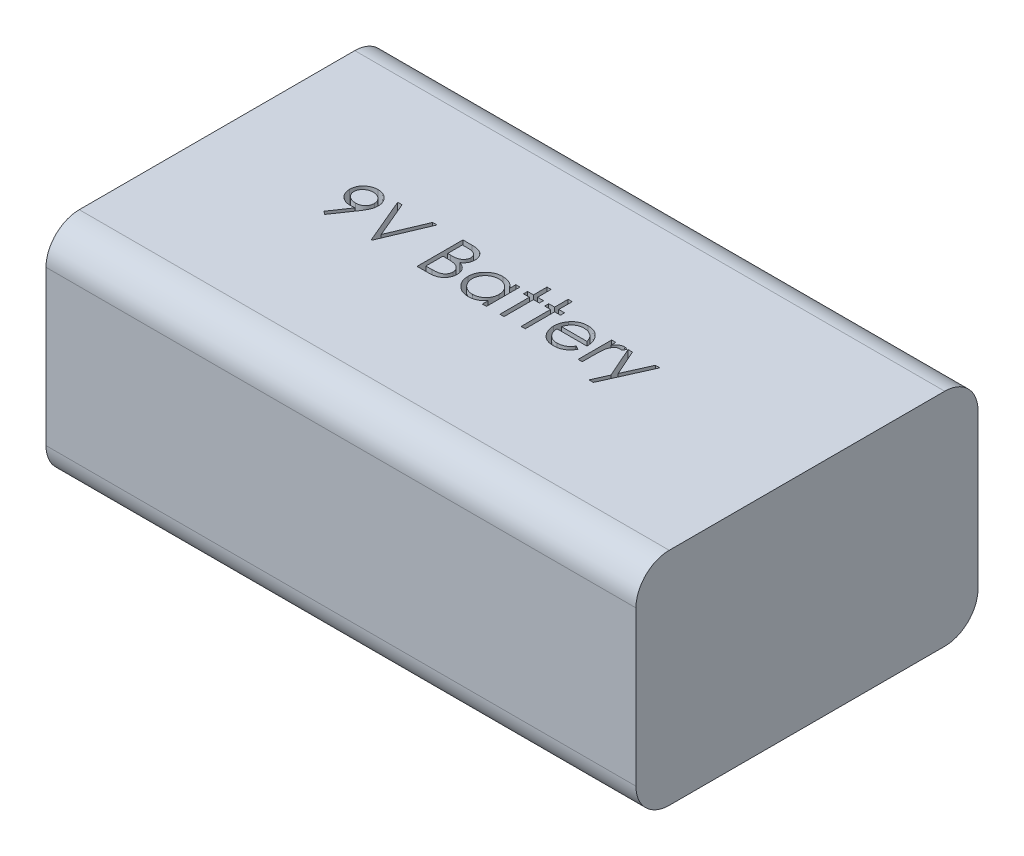
from build123d import *

# Parameters (mm, degrees)
SKETCH1_W           = 47.5742
SKETCH1_H           = 26.1112
BOSS_EXTRUDE1_DEPTH = 16.8656
CUT_EXTRUDE1_DEPTH  = 1.778
SKETCH3_W           = 26.1112
SKETCH3_H           = 16.8656
SKETCH3_R           = 3.81
CUT_EXTRUDE2_DEPTH  = 2.54
FILLET2_R           = 2.54


with BuildPart() as part:
    # Sketch1 → Boss-Extrude1 (new body)
    with BuildSketch(Plane(origin=(0, 0, 0), x_dir=(1, 0, 0), z_dir=(0, 1, 0))):
        with Locations((23.7871, 13.0556)):
            Rectangle(SKETCH1_W, SKETCH1_H)
    extrude(amount=BOSS_EXTRUDE1_DEPTH)

    # Sketch2 → Cut-Extrude1 (cut)
    with BuildSketch(Plane(origin=(0, 16.8656, 0), x_dir=(1, 0, 0), z_dir=(0, 1, 0))):
        with BuildLine():
            Line((12.226093924, 11.595445946), (11.975092322, 11.770025272))
            Line((11.975092322, 11.770025272), (12.948249373, 13.192601394))
            add(Edge.make_bspline(
                [(12.948249373, 13.192601394), (12.886158637, 13.185008331), (12.763898517, 13.170057166), (12.640761415, 13.167310511), (12.58016043, 13.165958766)],
                knots=[0, 0, 0, 0, 0.000187529, 0.000369255, 0.000369255, 0.000369255, 0.000369255], degree=3))
            add(Edge.make_bspline(
                [(12.58016043, 13.165958766), (12.543418383, 13.166899843), (12.471296956, 13.168747093), (12.365265303, 13.183388902), (12.263379743, 13.205939029), (12.165910387, 13.239587784), (12.072490882, 13.281405993), (11.983325169, 13.333263007), (11.898533278, 13.394269299), (11.819025868, 13.46410229), (11.746714129, 13.540780343), (11.682290831, 13.621935986), (11.6287497, 13.708511956), (11.584273114, 13.798742176), (11.550542661, 13.893923527), (11.525980123, 13.992972927), (11.510857769, 14.096584569), (11.509058673, 14.1671097), (11.508145206, 14.202917901)],
                knots=[0, 0, 0, 0, 0.000110185, 0.000216284, 0.000320547, 0.000422759, 0.000525058, 0.000627155, 0.000731643, 0.000837964, 0.0009441, 0.00104747, 0.001148247, 0.001248901, 0.001348697, 0.001450555, 0.001554666, 0.00166205, 0.00166205, 0.00166205, 0.00166205], degree=3))
            add(Edge.make_bspline(
                [(11.508145206, 14.202917901), (11.509879641, 14.251886553), (11.513283985, 14.348002085), (11.540682502, 14.488435854), (11.585742841, 14.621222398), (11.648571218, 14.746012591), (11.727705939, 14.861011331), (11.822814529, 14.96461994), (11.933318494, 15.055364794), (12.056700513, 15.133368871), (12.190053534, 15.196103868), (12.329722192, 15.242343169), (12.474636312, 15.269541917), (12.572803982, 15.273127778), (12.622227738, 15.274933125)],
                knots=[0, 0, 0, 0, 0.000146818, 0.000288173, 0.000427413, 0.000566316, 0.000705952, 0.000844895, 0.000986821, 0.001133677, 0.001281714, 0.001427825, 0.001574003, 0.00172222, 0.00172222, 0.00172222, 0.00172222], degree=3))
            add(Edge.make_bspline(
                [(12.622227738, 15.274933125), (12.670716158, 15.273102962), (12.766524705, 15.269486732), (12.907413711, 15.243002763), (13.042354728, 15.19836609), (13.170599715, 15.136681527), (13.289339127, 15.059360619), (13.396114938, 14.967226095), (13.488490477, 14.860220568), (13.566314358, 14.740932078), (13.628784398, 14.612765097), (13.673856681, 14.478981174), (13.70160232, 14.340542453), (13.705098647, 14.246747979), (13.706863155, 14.199412292)],
                knots=[0, 0, 0, 0, 0.000145418, 0.000287333, 0.000428343, 0.000570713, 0.000713061, 0.00085223, 0.000992387, 0.001135706, 0.001278381, 0.001418948, 0.001558239, 0.001700158, 0.001700158, 0.001700158, 0.001700158], degree=3))
            add(Edge.make_bspline(
                [(13.706863155, 14.199412292), (13.705684746, 14.162668525), (13.703294638, 14.088142984), (13.686558331, 13.974912641), (13.658138146, 13.859461412), (13.625886447, 13.761739816), (13.594754279, 13.681031366), (13.565453148, 13.617279786), (13.532940994, 13.550178523), (13.495022229, 13.480431185), (13.454259932, 13.40714865), (13.408200656, 13.331065934), (13.357895084, 13.252080941), (13.322065364, 13.198833853), (13.303718123, 13.17156774)],
                knots=[0, 0, 0, 0, 0.000110219, 0.000223552, 0.000342587, 0.000466527, 0.000532018, 0.000601997, 0.000676938, 0.00075567, 0.000840114, 0.000928491, 0.001022434, 0.001121023, 0.001121023, 0.001121023, 0.001121023], degree=3))
            Line((13.303718123, 13.17156774), (12.226093924, 11.595445946))
        make_face()
        with BuildLine():
            add(Edge.make_bspline(
                [(12.638353539, 13.524933125), (12.666187554, 13.525693509), (12.720370917, 13.527173717), (12.799748216, 13.536182959), (12.874672419, 13.552156945), (12.945343668, 13.575076658), (13.01247057, 13.602733326), (13.074986899, 13.637945313), (13.132944974, 13.679961947), (13.186732901, 13.727171963), (13.234496901, 13.779622547), (13.277039931, 13.834519653), (13.313200499, 13.892104263), (13.341763776, 13.953097526), (13.365248351, 14.016014734), (13.381466363, 14.081869089), (13.390450697, 14.15031749), (13.391982271, 14.196816148), (13.392760591, 14.220445946)],
                knots=[0, 0, 0, 0, 8.3507e-05, 0.00016256, 0.000239294, 0.000312908, 0.000385178, 0.000456751, 0.000527578, 0.000599603, 0.000671055, 0.000740051, 0.000807755, 0.000874553, 0.000941763, 0.001008931, 0.001077548, 0.001148448, 0.001148448, 0.001148448, 0.001148448], degree=3))
            add(Edge.make_bspline(
                [(13.392760591, 14.220445946), (13.392090922, 14.244085611), (13.390771256, 14.290670471), (13.380183957, 14.359220211), (13.361558733, 14.424913471), (13.336568249, 14.488109901), (13.303648011, 14.548290273), (13.264144525, 14.606210145), (13.217212075, 14.661502273), (13.163209509, 14.712866256), (13.104974956, 14.760214156), (13.042914456, 14.802000232), (12.97753954, 14.837021428), (12.90924905, 14.865920398), (12.837900701, 14.888472174), (12.763536713, 14.904689538), (12.685781308, 14.913661293), (12.633000021, 14.915183187), (12.606101937, 14.915958766)],
                knots=[0, 0, 0, 0, 7.09e-05, 0.000139717, 0.000207422, 0.000275384, 0.000343146, 0.000412766, 0.000485392, 0.000560268, 0.000636041, 0.000710323, 0.000784354, 0.000858188, 0.000932471, 0.001008519, 0.001086179, 0.001166885, 0.001166885, 0.001166885, 0.001166885], degree=3))
            add(Edge.make_bspline(
                [(12.606101937, 14.915958766), (12.579437784, 14.915181934), (12.527122934, 14.913657797), (12.450058775, 14.904706592), (12.376197607, 14.888363108), (12.305055987, 14.865930844), (12.236767526, 14.837019272), (12.171395693, 14.801998397), (12.109320677, 14.760223774), (12.051141956, 14.712829002), (11.997044034, 14.661741356), (11.950918505, 14.605967927), (11.911324613, 14.548320402), (11.87844961, 14.488101894), (11.853447093, 14.424915609), (11.834825091, 14.359219632), (11.824236926, 14.290670622), (11.822917379, 14.244085662), (11.82224777, 14.220445946)],
                knots=[0, 0, 0, 0, 8.0005e-05, 0.000156969, 0.000232332, 0.000306614, 0.000380449, 0.000454479, 0.000528762, 0.000604535, 0.000679411, 0.000751586, 0.000821205, 0.000888968, 0.00095693, 0.001024634, 0.001093451, 0.001164351, 0.001164351, 0.001164351, 0.001164351], degree=3))
            add(Edge.make_bspline(
                [(11.82224777, 14.220445946), (11.822853696, 14.196797747), (11.824048694, 14.150159171), (11.835576483, 14.081632778), (11.854854763, 14.015944584), (11.880674154, 13.952455877), (11.914675744, 13.891784019), (11.956399592, 13.834216657), (12.005305138, 13.779101207), (12.060738626, 13.727293995), (12.121406786, 13.679741819), (12.186203533, 13.638211437), (12.254013369, 13.603138993), (12.325075, 13.574997609), (12.3988618, 13.552385945), (12.476036932, 13.5362124), (12.556345169, 13.527260133), (12.610755151, 13.525716236), (12.638353539, 13.524933125)],
                knots=[0, 0, 0, 0, 7.09e-05, 0.000139828, 0.000207725, 0.00027595, 0.000345002, 0.000415829, 0.000488844, 0.000565728, 0.000643147, 0.000719775, 0.000796287, 0.0008718, 0.000948761, 0.001027552, 0.001107998, 0.001190805, 0.001190805, 0.001190805, 0.001190805], degree=3))
        make_face(mode=Mode.SUBTRACT)
        Polygon((14.200452898, 15.185189535), (14.53699136, 15.185189535), (15.703658027, 12.426976394), (16.870324693, 15.185189535), (17.206863155, 15.185189535), (15.726093924, 11.685189535), (15.681222129, 11.685189535), align=None)
        with BuildLine():
            Line((19.181222129, 15.185189535), (19.864114757, 15.185189535))
            add(Edge.make_bspline(
                [(19.864114757, 15.185189535), (19.897543236, 15.185013785), (19.962335946, 15.184673137), (20.056555388, 15.179390006), (20.144804198, 15.172186336), (20.227107971, 15.160756243), (20.303428673, 15.146964466), (20.37399631, 15.13026265), (20.438586483, 15.110236036), (20.515699219, 15.078389755), (20.60361988, 15.031066587), (20.698818273, 14.961138022), (20.780222512, 14.875605558), (20.850408829, 14.779122903), (20.906209949, 14.672987131), (20.946579246, 14.559727942), (20.972137122, 14.440806201), (20.974765556, 14.359163023), (20.976093924, 14.317901875)],
                knots=[0, 0, 0, 0, 0.00010027, 0.000194349, 0.000283026, 0.000365821, 0.000443519, 0.000515622, 0.000583254, 0.00064614, 0.000765662, 0.000881909, 0.000998927, 0.001118415, 0.001238844, 0.00135727, 0.001478274, 0.001601912, 0.001601912, 0.001601912, 0.001601912], degree=3))
            add(Edge.make_bspline(
                [(20.976093924, 14.317901875), (20.975000706, 14.279249319), (20.972852428, 14.203293402), (20.952309669, 14.092199293), (20.920149001, 13.986448074), (20.875443751, 13.886425689), (20.817341755, 13.794392076), (20.748483437, 13.70960481), (20.665406634, 13.635653753), (20.603163394, 13.59431085), (20.571546648, 13.573310529)],
                knots=[0, 0, 0, 0, 0.000115857, 0.00022767, 0.000337672, 0.000446877, 0.000555233, 0.000663318, 0.000773539, 0.000887324, 0.000887324, 0.000887324, 0.000887324], degree=3))
            add(Edge.make_bspline(
                [(20.571546648, 13.573310529), (20.611307076, 13.55804553), (20.687378623, 13.528839806), (20.792064636, 13.477204342), (20.882259481, 13.421042231), (20.958656627, 13.359710381), (21.023994282, 13.29360157), (21.081047223, 13.221746456), (21.129728597, 13.143207698), (21.171441521, 13.058804163), (21.203990277, 12.969397694), (21.228366181, 12.875826918), (21.242333631, 12.778427363), (21.244321272, 12.712141984), (21.245324693, 12.678679119)],
                knots=[0, 0, 0, 0, 0.000127722, 0.000244363, 0.000349599, 0.000445847, 0.000537565, 0.000627901, 0.000720503, 0.000814257, 0.000909859, 0.001005428, 0.001103887, 0.001204268, 0.001204268, 0.001204268, 0.001204268], degree=3))
            add(Edge.make_bspline(
                [(21.245324693, 12.678679119), (21.244347847, 12.644512246), (21.242425875, 12.577287968), (21.228245904, 12.478532834), (21.204236797, 12.384157887), (21.17116565, 12.293552705), (21.128003336, 12.20689257), (21.075475371, 12.124079306), (21.012843808, 12.045944975), (20.942780939, 11.971621352), (20.863518793, 11.904793565), (20.778003038, 11.845277858), (20.685156718, 11.796331796), (20.586504724, 11.755215775), (20.480940408, 11.723808576), (20.368937801, 11.701836002), (20.250593499, 11.687030965), (20.169383748, 11.68581376), (20.127736552, 11.685189535)],
                knots=[0, 0, 0, 0, 0.000102481, 0.000201635, 0.000298562, 0.000394165, 0.000490425, 0.000588455, 0.000687769, 0.000790423, 0.000894381, 0.000998232, 0.001102369, 0.001208616, 0.001318415, 0.001432129, 0.001550749, 0.00167562, 0.00167562, 0.00167562, 0.00167562], degree=3))
            Line((20.127736552, 11.685189535), (19.181222129, 11.685189535))
            Line((19.181222129, 11.685189535), (19.181222129, 15.185189535))
        make_face()
        with BuildLine():
            Line((19.495324693, 14.826215176), (19.495324693, 13.704420305))
            Line((19.495324693, 13.704420305), (19.706362354, 13.704420305))
            add(Edge.make_bspline(
                [(19.706362354, 13.704420305), (19.737211149, 13.704820228), (19.796817308, 13.70559296), (19.883137205, 13.707806477), (19.963262223, 13.714004521), (20.037054056, 13.720200783), (20.1043965, 13.73027537), (20.165140361, 13.742267493), (20.220238958, 13.754950398), (20.283778504, 13.776519885), (20.355851452, 13.808397561), (20.432684557, 13.857869397), (20.500419026, 13.91679375), (20.557616214, 13.984784712), (20.604427684, 14.059650897), (20.6369414, 14.140197778), (20.658988684, 14.22441791), (20.660980215, 14.282236163), (20.66199136, 14.311591779)],
                knots=[0, 0, 0, 0, 9.2559e-05, 0.000178842, 0.000258967, 0.000333616, 0.000400942, 0.000463093, 0.000519379, 0.000570374, 0.000664201, 0.000755025, 0.000843472, 0.000932526, 0.001020669, 0.001107124, 0.001192318, 0.001280185, 0.001280185, 0.001280185, 0.001280185], degree=3))
            add(Edge.make_bspline(
                [(20.66199136, 14.311591779), (20.66146518, 14.33101755), (20.66043302, 14.369123322), (20.651979717, 14.424672677), (20.637612143, 14.476916429), (20.61915785, 14.526570539), (20.593369161, 14.57208239), (20.563005698, 14.615025585), (20.526320007, 14.653937704), (20.484562695, 14.690307202), (20.436554072, 14.72255173), (20.38232278, 14.750792493), (20.321135103, 14.77353327), (20.254022248, 14.793449422), (20.17995116, 14.807437716), (20.099776607, 14.819091104), (20.012841888, 14.825023846), (19.952696785, 14.825809209), (19.921606745, 14.826215176)],
                knots=[0, 0, 0, 0, 5.8261e-05, 0.000114285, 0.000168029, 0.000220632, 0.000272728, 0.000324483, 0.000378062, 0.000432741, 0.000490301, 0.000551137, 0.000615721, 0.000685833, 0.000760908, 0.00084162, 0.000928788, 0.00102206, 0.00102206, 0.00102206, 0.00102206], degree=3))
            Line((19.921606745, 14.826215176), (19.495324693, 14.826215176))
        make_face(mode=Mode.SUBTRACT)
        with BuildLine():
            Line((19.495324693, 13.345445946), (19.495324693, 12.044163894))
            Line((19.495324693, 12.044163894), (19.942640398, 12.044163894))
            add(Edge.make_bspline(
                [(19.942640398, 12.044163894), (19.974659324, 12.044547642), (20.036371583, 12.045287264), (20.125472813, 12.047701819), (20.208055917, 12.053194094), (20.283744053, 12.061839944), (20.353354505, 12.071218393), (20.416052208, 12.083829674), (20.472345402, 12.098278635), (20.537619709, 12.120612807), (20.611123218, 12.155309278), (20.690334074, 12.207623504), (20.760760292, 12.269946812), (20.820565551, 12.342077726), (20.86957854, 12.420509053), (20.905233995, 12.503654403), (20.927224852, 12.590139931), (20.929887021, 12.649106643), (20.931222129, 12.678679119)],
                knots=[0, 0, 0, 0, 9.6064e-05, 0.000185151, 0.000267373, 0.000344257, 0.000413665, 0.000478015, 0.000536005, 0.000587888, 0.000684801, 0.000778918, 0.000871787, 0.000965866, 0.001059062, 0.00114827, 0.001236355, 0.001324974, 0.001324974, 0.001324974, 0.001324974], degree=3))
            add(Edge.make_bspline(
                [(20.931222129, 12.678679119), (20.930946025, 12.697172459), (20.93039827, 12.733860841), (20.922137655, 12.78777666), (20.910123785, 12.840002533), (20.894592351, 12.890680274), (20.871972884, 12.93889365), (20.845566339, 12.98559621), (20.814604937, 13.030849689), (20.766360772, 13.088061943), (20.696188787, 13.153978956), (20.596482012, 13.218516458), (20.483109714, 13.270564265), (20.400882221, 13.292663741), (20.358405623, 13.30407976)],
                knots=[0, 0, 0, 0, 5.5429e-05, 0.000109963, 0.000163198, 0.000216191, 0.000268588, 0.000322593, 0.000377046, 0.000432793, 0.000546889, 0.000664343, 0.000787646, 0.000919405, 0.000919405, 0.000919405, 0.000919405], degree=3))
            add(Edge.make_bspline(
                [(20.358405623, 13.30407976), (20.341376527, 13.307534844), (20.304453935, 13.315026178), (20.244246354, 13.322933882), (20.175510485, 13.329978942), (20.098087608, 13.335190099), (20.011879767, 13.340576643), (19.916702848, 13.342671464), (19.812945534, 13.345170724), (19.740953161, 13.345351858), (19.703557866, 13.345445946)],
                knots=[0, 0, 0, 0, 5.2115e-05, 0.000112995, 0.000182062, 0.000259389, 0.000345767, 0.00044116, 0.000544948, 0.000657129, 0.000657129, 0.000657129, 0.000657129], degree=3))
            Line((19.703557866, 13.345445946), (19.495324693, 13.345445946))
        make_face(mode=Mode.SUBTRACT)
        with BuildLine():
            Line((24.476093924, 14.242881843), (24.476093924, 11.685189535))
            Line((24.476093924, 11.685189535), (24.16199136, 11.685189535))
            Line((24.16199136, 11.685189535), (24.16199136, 12.127597388))
            add(Edge.make_bspline(
                [(24.16199136, 12.127597388), (24.126572569, 12.087557794), (24.057452354, 12.009420023), (23.942011236, 11.90733785), (23.819643058, 11.822959529), (23.690941737, 11.754809613), (23.556023494, 11.703617557), (23.415187406, 11.667231398), (23.268376026, 11.643837562), (23.168123671, 11.641501541), (23.117319886, 11.64031774)],
                knots=[0, 0, 0, 0, 0.000160263, 0.000312755, 0.000460949, 0.000605216, 0.000748578, 0.000892786, 0.001041028, 0.001193333, 0.001193333, 0.001193333, 0.001193333], degree=3))
            add(Edge.make_bspline(
                [(23.117319886, 11.64031774), (23.072151932, 11.641544113), (22.983078727, 11.643962573), (22.85204965, 11.662724877), (22.7259574, 11.692855498), (22.604682828, 11.734756388), (22.489010682, 11.790337209), (22.377950586, 11.856878458), (22.272077894, 11.936119288), (22.173006355, 12.026707316), (22.081774354, 12.125102303), (22.001713082, 12.23004785), (21.934960002, 12.341090154), (21.879139921, 12.456823308), (21.836143577, 12.578138227), (21.806169942, 12.704615395), (21.787429496, 12.836105269), (21.785012035, 12.925644792), (21.783786232, 12.971046907)],
                knots=[0, 0, 0, 0, 0.000135464, 0.00026714, 0.000396211, 0.000523931, 0.000651257, 0.000780517, 0.000911767, 0.001047265, 0.00118272, 0.001313831, 0.001442491, 0.001570752, 0.001698704, 0.001827775, 0.001960146, 0.00209631, 0.00209631, 0.00209631, 0.00209631], degree=3))
            add(Edge.make_bspline(
                [(21.783786232, 12.971046907), (21.785039203, 13.015510611), (21.78751626, 13.103412954), (21.80596948, 13.232691652), (21.837000488, 13.357209913), (21.880548336, 13.476566856), (21.936390291, 13.590906906), (22.004318378, 13.700310931), (22.084337503, 13.805080329), (22.17658991, 13.902751555), (22.27652468, 13.99297217), (22.383433411, 14.071381215), (22.494656692, 14.139098064), (22.611919703, 14.19275154), (22.733486808, 14.236160645), (22.860440253, 14.266193613), (22.992251832, 14.283890934), (23.081742324, 14.286453698), (23.127135591, 14.287753638)],
                knots=[0, 0, 0, 0, 0.000133363, 0.00026365, 0.000390846, 0.000517716, 0.000644083, 0.000771912, 0.000903449, 0.001038867, 0.001174416, 0.001306792, 0.001436052, 0.00156435, 0.001692963, 0.001822716, 0.001954992, 0.002091156, 0.002091156, 0.002091156, 0.002091156], degree=3))
            add(Edge.make_bspline(
                [(23.127135591, 14.287753638), (23.17933545, 14.286315886), (23.28169691, 14.283496523), (23.431424919, 14.260033796), (23.573069397, 14.220395329), (23.707723749, 14.166477831), (23.834904435, 14.094829102), (23.953407419, 14.004449141), (24.064472903, 13.895907954), (24.128853194, 13.812537509), (24.16199136, 13.769624631)],
                knots=[0, 0, 0, 0, 0.00015654, 0.000306968, 0.000453261, 0.000596998, 0.000741098, 0.000889738, 0.001042937, 0.001205434, 0.001205434, 0.001205434, 0.001205434], degree=3))
            Line((24.16199136, 13.769624631), (24.16199136, 14.242881843))
            Line((24.16199136, 14.242881843), (24.476093924, 14.242881843))
        make_face()
        with BuildLine():
            add(Edge.make_bspline(
                [(23.131342322, 13.973651074), (23.085427984, 13.972017436), (22.994800384, 13.968792895), (22.861756382, 13.9436194), (22.734442968, 13.901734805), (22.613496893, 13.844452904), (22.500828677, 13.772424168), (22.400135006, 13.685302784), (22.310592304, 13.58546577), (22.23528404, 13.47336366), (22.173893543, 13.353185569), (22.130726511, 13.227561131), (22.102257264, 13.098756153), (22.099348743, 13.011393467), (22.097888796, 12.967541298)],
                knots=[0, 0, 0, 0, 0.000137677, 0.000271753, 0.000404561, 0.000538791, 0.000672205, 0.000804452, 0.00093703, 0.001073348, 0.00120849, 0.001340643, 0.001470999, 0.001602378, 0.001602378, 0.001602378, 0.001602378], degree=3))
            add(Edge.make_bspline(
                [(22.097888796, 12.967541298), (22.099753689, 12.923951191), (22.103476166, 12.836941835), (22.13022686, 12.707961258), (22.175106734, 12.582307216), (22.236348797, 12.461046223), (22.313035421, 12.348462122), (22.401924074, 12.246722), (22.503874355, 12.159232412), (22.616801862, 12.085994838), (22.737409833, 12.026832317), (22.864243764, 11.985666677), (22.994919402, 11.959088897), (23.083771736, 11.95598442), (23.128537834, 11.954420305)],
                knots=[0, 0, 0, 0, 0.000130727, 0.000260941, 0.000393327, 0.000530037, 0.000667328, 0.000800955, 0.000934191, 0.001068956, 0.001203792, 0.001335934, 0.001468075, 0.001602253, 0.001602253, 0.001602253, 0.001602253], degree=3))
            add(Edge.make_bspline(
                [(23.128537834, 11.954420305), (23.173984337, 11.956080268), (23.264372924, 11.959381772), (23.397811632, 11.984663037), (23.527306594, 12.026431836), (23.651093823, 12.084330962), (23.766409954, 12.156088318), (23.869907831, 12.240095409), (23.9574238, 12.337798593), (24.031616409, 12.445175047), (24.089791826, 12.562887043), (24.132167885, 12.688221234), (24.157221791, 12.821181982), (24.160379521, 12.912045909), (24.16199136, 12.958426715)],
                knots=[0, 0, 0, 0, 0.000136278, 0.000271043, 0.000405851, 0.000543552, 0.000679927, 0.000812429, 0.000941985, 0.001072088, 0.00120284, 0.001334538, 0.001467925, 0.001607002, 0.001607002, 0.001607002, 0.001607002], degree=3))
            add(Edge.make_bspline(
                [(24.16199136, 12.958426715), (24.161031704, 12.993764545), (24.159142796, 13.063320579), (24.144712227, 13.165448096), (24.1217573, 13.263181822), (24.08941113, 13.356624511), (24.046919846, 13.445259527), (23.99567208, 13.529723287), (23.93476663, 13.609576498), (23.865183934, 13.683719569), (23.789018732, 13.751346032), (23.708424191, 13.811710272), (23.622445444, 13.861299045), (23.532528407, 13.902340316), (23.438517073, 13.934999466), (23.339646453, 13.95678716), (23.236967466, 13.971747481), (23.16692141, 13.973009862), (23.131342322, 13.973651074)],
                knots=[0, 0, 0, 0, 0.000105983, 0.000208608, 0.000308773, 0.00040678, 0.000504626, 0.000603105, 0.000702667, 0.00080535, 0.000907651, 0.001007914, 0.001106881, 0.00120477, 0.001304102, 0.001404791, 0.00150811, 0.001614764, 0.001614764, 0.001614764, 0.001614764], degree=3))
        make_face(mode=Mode.SUBTRACT)
        Polygon((25.508145206, 15.274933125), (25.82224777, 15.274933125), (25.82224777, 14.242881843), (26.270965719, 14.242881843), (26.270965719, 13.928779279), (25.82224777, 13.928779279), (25.82224777, 11.685189535), (25.508145206, 11.685189535), (25.508145206, 13.928779279), (25.059427257, 13.928779279), (25.059427257, 14.242881843), (25.508145206, 14.242881843), align=None)
        Polygon((27.123529822, 15.274933125), (27.437632386, 15.274933125), (27.437632386, 14.242881843), (27.886350334, 14.242881843), (27.886350334, 13.928779279), (27.437632386, 13.928779279), (27.437632386, 11.685189535), (27.123529822, 11.685189535), (27.123529822, 13.928779279), (26.674811873, 13.928779279), (26.674811873, 14.242881843), (27.123529822, 14.242881843), align=None)
        with BuildLine():
            Line((30.523970527, 12.492881843), (30.803017001, 12.346347388))
            add(Edge.make_bspline(
                [(30.803017001, 12.346347388), (30.780780406, 12.306904057), (30.737516797, 12.230162954), (30.663116049, 12.124731093), (30.585123977, 12.029883377), (30.500020009, 11.948153723), (30.41035033, 11.876902338), (30.315617675, 11.814564513), (30.215328857, 11.761445993), (30.109479133, 11.716693465), (29.997179581, 11.682283971), (29.878158065, 11.65797975), (29.75218657, 11.642956482), (29.66584039, 11.641211341), (29.621626777, 11.64031774)],
                knots=[0, 0, 0, 0, 0.000135759, 0.000264133, 0.000386579, 0.000503597, 0.000617365, 0.000729763, 0.000843304, 0.000957371, 0.001074023, 0.001195027, 0.001321389, 0.001453992, 0.001453992, 0.001453992, 0.001453992], degree=3))
            add(Edge.make_bspline(
                [(29.621626777, 11.64031774), (29.572484799, 11.641464916), (29.476623037, 11.643702722), (29.33708329, 11.662995187), (29.205703872, 11.694467546), (29.082492169, 11.738433087), (28.967749916, 11.795860411), (28.861249061, 11.865819893), (28.762429535, 11.947952148), (28.674405326, 12.042968591), (28.595161443, 12.144650548), (28.525235623, 12.250606433), (28.466778192, 12.360569657), (28.419225582, 12.473840181), (28.380820717, 12.589704075), (28.354054013, 12.709215543), (28.338624265, 12.832051127), (28.33625982, 12.915148463), (28.335068283, 12.957024471)],
                knots=[0, 0, 0, 0, 0.000147371, 0.000287478, 0.000421649, 0.000552053, 0.000679042, 0.000805636, 0.000933558, 0.00106351, 0.001193382, 0.001319977, 0.001443869, 0.001566405, 0.001688128, 0.001809576, 0.001933238, 0.002058864, 0.002058864, 0.002058864, 0.002058864], degree=3))
            add(Edge.make_bspline(
                [(28.335068283, 12.957024471), (28.336127424, 12.996319302), (28.338226503, 13.074196466), (28.35145729, 13.189462011), (28.374905583, 13.301490463), (28.407081907, 13.410374911), (28.448633153, 13.515933045), (28.499465372, 13.618229109), (28.55965775, 13.717154249), (28.606130424, 13.779557382), (28.629539437, 13.810990817)],
                knots=[0, 0, 0, 0, 0.000117891, 0.000233644, 0.000347498, 0.000460856, 0.000573868, 0.000687374, 0.000803169, 0.000920699, 0.000920699, 0.000920699, 0.000920699], degree=3))
            add(Edge.make_bspline(
                [(28.629539437, 13.810990817), (28.66124712, 13.848859687), (28.723658066, 13.923397838), (28.829214422, 14.021336164), (28.943514618, 14.103379939), (29.065126244, 14.171387075), (29.195462718, 14.223060722), (29.332772009, 14.261568304), (29.478617595, 14.283146315), (29.578322816, 14.286194149), (29.629339116, 14.287753638)],
                knots=[0, 0, 0, 0, 0.000148071, 0.000291452, 0.00043058, 0.000569298, 0.000708346, 0.00085021, 0.000996268, 0.001149307, 0.001149307, 0.001149307, 0.001149307], degree=3))
            add(Edge.make_bspline(
                [(29.629339116, 14.287753638), (29.681786722, 14.286399589), (29.784676968, 14.283743254), (29.934709089, 14.25911692), (30.076669805, 14.220064366), (30.21050231, 14.164910575), (30.33622017, 14.093751023), (30.45300622, 14.005609182), (30.562857732, 13.903191095), (30.626766311, 13.824427885), (30.659287033, 13.784348189)],
                knots=[0, 0, 0, 0, 0.000157241, 0.00030847, 0.000454763, 0.000598116, 0.000741606, 0.000886879, 0.001036172, 0.001190853, 0.001190853, 0.001190853, 0.001190853], degree=3))
            add(Edge.make_bspline(
                [(30.659287033, 13.784348189), (30.681413971, 13.754144608), (30.725520564, 13.693938489), (30.780767665, 13.595767332), (30.828725059, 13.493056738), (30.867058021, 13.384146441), (30.898097522, 13.27032686), (30.92055434, 13.150784316), (30.933723959, 13.025554404), (30.936312656, 12.940227849), (30.937632386, 12.896727997)],
                knots=[0, 0, 0, 0, 0.000112234, 0.000223721, 0.000337279, 0.000451932, 0.000569628, 0.000690912, 0.000816421, 0.00094695, 0.00094695, 0.00094695, 0.00094695], degree=3))
            Line((30.937632386, 12.896727997), (28.649170847, 12.896727997))
            add(Edge.make_bspline(
                [(28.649170847, 12.896727997), (28.650710454, 12.863027533), (28.653738028, 12.796756929), (28.667853171, 12.699786146), (28.690101944, 12.607412804), (28.721371007, 12.520329762), (28.759237852, 12.437399634), (28.805623569, 12.359237597), (28.860963123, 12.286199667), (28.922688822, 12.217632529), (28.991395918, 12.156571768), (29.063678665, 12.101919992), (29.14057223, 12.056114395), (29.221470314, 12.018934506), (29.306242099, 11.98982819), (29.394914294, 11.969960369), (29.48731241, 11.956653262), (29.550298144, 11.955173597), (29.582363956, 11.954420305)],
                knots=[0, 0, 0, 0, 0.000101159, 0.000198924, 0.000293472, 0.000385722, 0.000476069, 0.000566611, 0.000657757, 0.000750573, 0.000842919, 0.000933083, 0.001022062, 0.001110842, 0.001199752, 0.001290403, 0.001383113, 0.001479259, 0.001479259, 0.001479259, 0.001479259], degree=3))
            add(Edge.make_bspline(
                [(29.582363956, 11.954420305), (29.613715104, 11.955028361), (29.675921795, 11.956234862), (29.768562652, 11.967966773), (29.859702179, 11.986937049), (29.948963163, 12.012827039), (30.034534009, 12.044403891), (30.113779559, 12.082506749), (30.186659774, 12.124656495), (30.254776741, 12.17286617), (30.320847734, 12.231874357), (30.386390221, 12.305510078), (30.456666874, 12.392597606), (30.500656467, 12.458143272), (30.523970527, 12.492881843)],
                knots=[0, 0, 0, 0, 9.4016e-05, 0.000186545, 0.000279636, 0.000373054, 0.000465125, 0.000552934, 0.000636508, 0.000717442, 0.000802858, 0.000901616, 0.001012865, 0.001138311, 0.001138311, 0.001138311, 0.001138311], degree=3))
        make_face()
        with BuildLine():
            add(Edge.make_bspline(
                [(30.623529822, 13.210830561), (30.612033197, 13.252493435), (30.589905895, 13.332681055), (30.543669531, 13.443721946), (30.49159799, 13.542409847), (30.429976259, 13.62798948), (30.360157533, 13.703992993), (30.279512351, 13.770411578), (30.189076457, 13.829829029), (30.089317317, 13.879981528), (29.983675531, 13.922671387), (29.873069339, 13.951296503), (29.760211552, 13.970906045), (29.683877265, 13.972732154), (29.645464918, 13.973651074)],
                knots=[0, 0, 0, 0, 0.000129543, 0.000249328, 0.000360065, 0.000463575, 0.000564789, 0.000668832, 0.000776175, 0.000888744, 0.001003316, 0.001117263, 0.001230914, 0.001346035, 0.001346035, 0.001346035, 0.001346035], degree=3))
            add(Edge.make_bspline(
                [(29.645464918, 13.973651074), (29.614115479, 13.973039402), (29.55214423, 13.971830256), (29.460843162, 13.960360127), (29.373163463, 13.941400282), (29.288458175, 13.915435325), (29.207837307, 13.880826723), (29.129642539, 13.840243496), (29.055862143, 13.790701912), (29.009720847, 13.752943058), (28.98641043, 13.73386742)],
                knots=[0, 0, 0, 0, 9.4016e-05, 0.000185849, 0.000275511, 0.000362884, 0.000451173, 0.00053836, 0.000626838, 0.000717174, 0.000717174, 0.000717174, 0.000717174], degree=3))
            add(Edge.make_bspline(
                [(28.98641043, 13.73386742), (28.969717149, 13.718773104), (28.935934014, 13.688225888), (28.890793493, 13.635596682), (28.84757302, 13.57884512), (28.808239367, 13.515799995), (28.772161781, 13.447179216), (28.738401804, 13.373561581), (28.708015392, 13.29438845), (28.690919282, 13.239216011), (28.682123572, 13.210830561)],
                knots=[0, 0, 0, 0, 6.7454e-05, 0.00013651, 0.000207604, 0.000281328, 0.000359112, 0.000440057, 0.000524171, 0.000613305, 0.000613305, 0.000613305, 0.000613305], degree=3))
            Line((28.682123572, 13.210830561), (30.623529822, 13.210830561))
        make_face(mode=Mode.SUBTRACT)
        with BuildLine():
            Line((31.476093924, 14.242881843), (31.790196488, 14.242881843))
            Line((31.790196488, 14.242881843), (31.790196488, 13.866379439))
            add(Edge.make_bspline(
                [(31.790196488, 13.866379439), (31.813385247, 13.901435267), (31.857733568, 13.968479267), (31.931446497, 14.057148568), (32.006949829, 14.130563614), (32.084605016, 14.189067133), (32.164983116, 14.232880252), (32.246320067, 14.264973287), (32.329895537, 14.283950602), (32.386057462, 14.286484261), (32.414194886, 14.287753638)],
                knots=[0, 0, 0, 0, 0.000126023, 0.000241017, 0.000345147, 0.000441342, 0.00053171, 0.000618946, 0.000702978, 0.000787349, 0.000787349, 0.000787349, 0.000787349], degree=3))
            add(Edge.make_bspline(
                [(32.414194886, 14.287753638), (32.436021212, 14.286563111), (32.480930297, 14.284113525), (32.548912887, 14.266902701), (32.618956339, 14.239424678), (32.664098726, 14.213584456), (32.687632386, 14.200113413)],
                knots=[0, 0, 0, 0, 6.5445e-05, 0.000134658, 0.00020926, 0.000290509, 0.000290509, 0.000290509, 0.000290509], degree=3))
            Line((32.687632386, 14.200113413), (32.515156424, 13.928078157))
            add(Edge.make_bspline(
                [(32.515156424, 13.928078157), (32.500047403, 13.934818423), (32.471367588, 13.947612739), (32.429413022, 13.962754749), (32.390731685, 13.971670665), (32.366088127, 13.973021382), (32.354599533, 13.973651074)],
                knots=[0, 0, 0, 0, 4.9621e-05, 9.4191e-05, 0.00013366, 0.000168129, 0.000168129, 0.000168129, 0.000168129], degree=3))
            add(Edge.make_bspline(
                [(32.354599533, 13.973651074), (32.3293938, 13.971971036), (32.27798141, 13.968544247), (32.20249691, 13.941605439), (32.129249705, 13.898080199), (32.071078042, 13.849809087), (32.026035789, 13.80326129), (31.993895564, 13.762612887), (31.964412817, 13.717034256), (31.936242597, 13.667304572), (31.910576302, 13.612574726), (31.886621633, 13.553391513), (31.86496277, 13.489686384), (31.852612526, 13.445303864), (31.846286232, 13.422569343)],
                knots=[0, 0, 0, 0, 7.549e-05, 0.000153978, 0.000237553, 0.000330197, 0.000379784, 0.000431685, 0.000485357, 0.000542493, 0.000603021, 0.000666557, 0.00073396, 0.000804745, 0.000804745, 0.000804745, 0.000804745], degree=3))
            add(Edge.make_bspline(
                [(31.846286232, 13.422569343), (31.841553838, 13.402292169), (31.831071947, 13.357379771), (31.820880409, 13.282031246), (31.810810891, 13.193007587), (31.803714273, 13.090060994), (31.79713623, 12.97344855), (31.793426148, 12.842992605), (31.790323008, 12.698559254), (31.790239941, 12.5975849), (31.790196488, 12.544764856)],
                knots=[0, 0, 0, 0, 6.2435e-05, 0.000138289, 0.000227871, 0.000331224, 0.000447781, 0.000578258, 0.000722716, 0.000881171, 0.000881171, 0.000881171, 0.000881171], degree=3))
            Line((31.790196488, 12.544764856), (31.790196488, 11.685189535))
            Line((31.790196488, 11.685189535), (31.476093924, 11.685189535))
            Line((31.476093924, 11.685189535), (31.476093924, 14.242881843))
        make_face()
        Polygon((32.73250418, 14.242881843), (33.071146007, 14.242881843), (33.937031424, 12.283947548), (34.816238155, 14.242881843), (35.155581104, 14.242881843), (33.585068283, 10.742881843), (33.245725334, 10.742881843), (33.766658828, 11.903238413), align=None)
    extrude(amount=-CUT_EXTRUDE1_DEPTH, mode=Mode.SUBTRACT)

    # Sketch3 → Cut-Extrude2 (cut)
    with BuildSketch(Plane.ZY):
        with Locations((-13.0556, 8.4328)):
            Rectangle(SKETCH3_W, SKETCH3_H)
        with Locations((-19.5834, 8.4328)):
            Circle(SKETCH3_R, mode=Mode.SUBTRACT)
        with Locations((-6.5278, 8.4328)):
            Circle(SKETCH3_R, mode=Mode.SUBTRACT)
    extrude(amount=-CUT_EXTRUDE2_DEPTH, mode=Mode.SUBTRACT)

    # Fillet2
    fillet2_edges = [part.edges().sort_by_distance(p)[0] for p in [
        (25.0571, 16.8656, -26.1112),
        (25.0571, 0, 0),
        (25.0571, 16.8656, 0),
        (25.0571, 0, -26.1112),
    ]]
    fillet(fillet2_edges, radius=FILLET2_R)


solid = part.part
